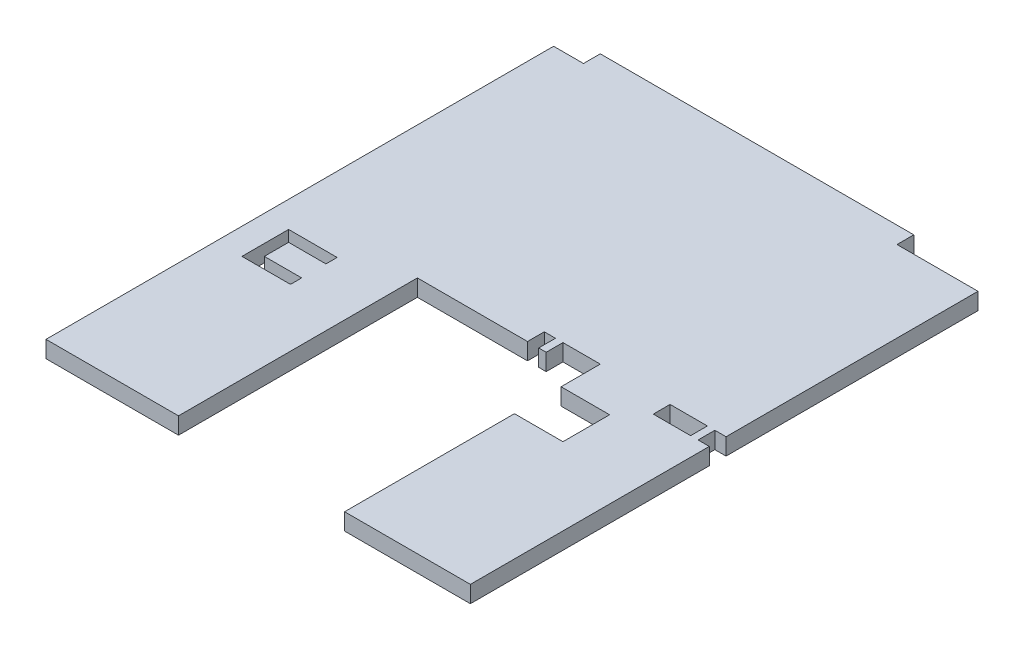
from build123d import *

# Parameters (mm, degrees)
SKETCH2_W           = 10
SKETCH2_H           = 4.5
BOSS_EXTRUDE1_DEPTH = 4.5


with BuildPart() as part:
    # Sketch2 → Boss-Extrude1 (new body)
    with BuildSketch(Plane(origin=(0, 0, 0), x_dir=(1, 0, 0), z_dir=(0, 1, 0))):
        Polygon((11.295466324, 4.5), (11.295466324, 0), (-18.204533676, 0), (-18.204533676, -64), (-53.704533676, -64), (-53.704533676, 72), (-45.704533676, 72), (-45.704533676, 76.5), (38.295466324, 76.5), (38.295466324, 72), (59.995466324, 72), (59.995466324, 4.5), (56.995466324, 4.5), (56.995466324, 0), (59.995466324, 0), (59.995466324, -64), (26.295466324, -64), (26.295466324, -18.5), (39.295466324, -18.5), (39.295466324, -6), (26.295466324, -6), (26.295466324, 4.5), (16.295466324, 4.5), (16.295466324, 0), (14.295466324, 0), (14.295466324, 4.5), align=None)
        with Locations((49.995466324, 2.25)):
            Rectangle(SKETCH2_W, SKETCH2_H, mode=Mode.SUBTRACT)
        Polygon((-33.704533676, -15.5), (-33.704533676, -18.5), (-46.704533676, -18.5), (-46.704533676, -6), (-33.704533676, -6), (-33.704533676, -9), (-43.704533676, -9), (-43.704533676, -15.5), align=None, mode=Mode.SUBTRACT)
    extrude(amount=BOSS_EXTRUDE1_DEPTH)


solid = part.part
